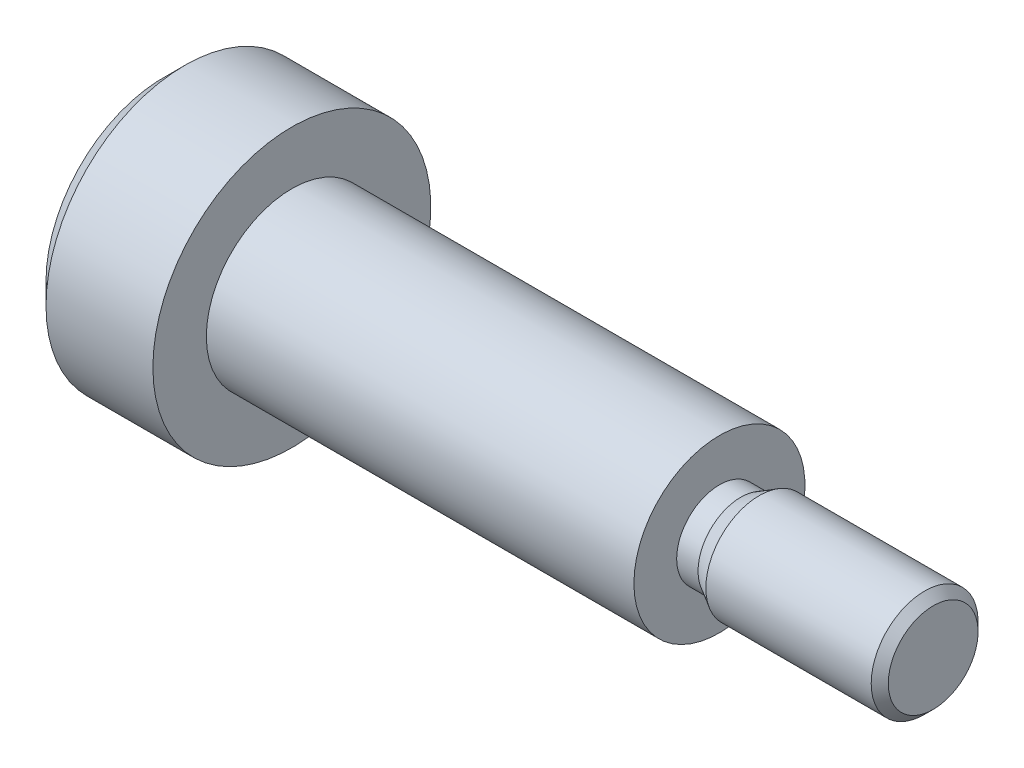
from build123d import *

# Parameters (mm, degrees)
FASE1_SIZE = 0.5
FASE2_SIZE = 0.2


with BuildPart() as part:
    # Skizze1 → Rotation1 (revolve)
    with BuildSketch(Plane.XY):
        Polygon((0, 0), (0, 3.25), (3, 3.25), (3, 2), (13, 2), (13, 1.25), (18, 1.25), (18, 0), align=None)
    revolve(axis=Axis((0, 0, 0), (1, 0, 0)))

    # Fase1
    fase1_edges = [part.edges().sort_by_distance(p)[0] for p in [
        (0, -3.25, 0),
    ]]
    chamfer(fase1_edges, length=FASE1_SIZE)

    # Fase2
    fase2_edges = [part.edges().sort_by_distance(p)[0] for p in [
        (18, -1.25, 0),
    ]]
    chamfer(fase2_edges, length=FASE2_SIZE)

    # Skizze2 → Schnitt-Rotation1 (revolve, cut)
    with BuildSketch(Plane.XY):
        Polygon((13, 1.25), (13, 1), (13.5, 1), (13.933012702, 1.25), align=None)
    revolve(axis=Axis((0, 0, 0), (1, 0, 0)), mode=Mode.SUBTRACT)


solid = part.part
